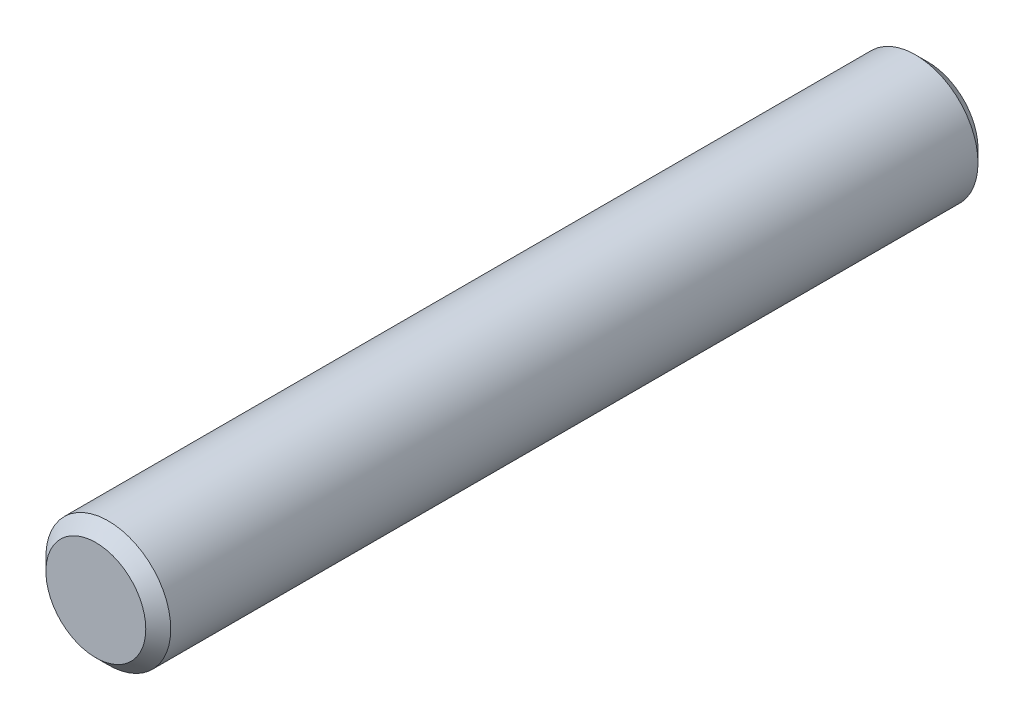
from build123d import *

# Parameters (mm, degrees)
SKETCH1_R           = 1.5
BOSS_EXTRUDE1_DEPTH = 10
CHAMFER1_SIZE       = 0.3


with BuildPart() as part:
    # Sketch1 → Boss-Extrude1 (new body, symmetric)
    with BuildSketch(Plane.XY):
        Circle(SKETCH1_R)
    extrude(amount=BOSS_EXTRUDE1_DEPTH, both=True)

    # Chamfer1
    chamfer1_edges = [part.edges().sort_by_distance(p)[0] for p in [
        (-1.5, 0, -10),
        (-1.5, 0, 10),
    ]]
    chamfer(chamfer1_edges, length=CHAMFER1_SIZE)


solid = part.part
